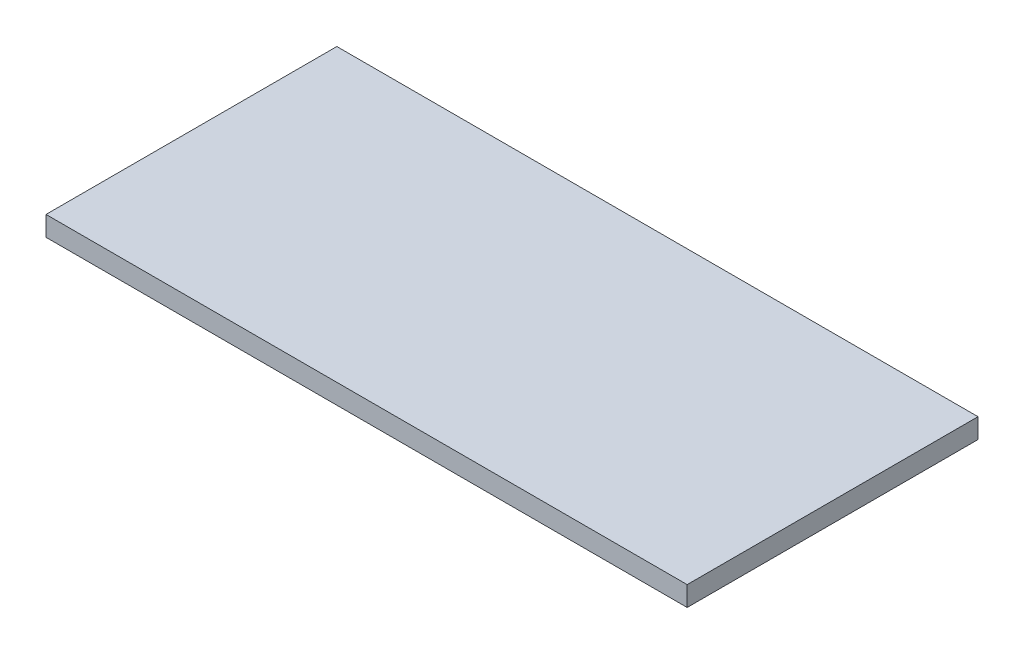
from build123d import *

# Parameters (mm, degrees)
SKETCH1_W           = 97
SKETCH1_H           = 44
BOSS_EXTRUDE1_DEPTH = 3


with BuildPart() as part:
    # Sketch1 → Boss-Extrude1 (new body)
    with BuildSketch(Plane(origin=(0, 0, 0), x_dir=(1, 0, 0), z_dir=(0, 1, 0))):
        Rectangle(SKETCH1_W, SKETCH1_H)
    extrude(amount=BOSS_EXTRUDE1_DEPTH)


solid = part.part
